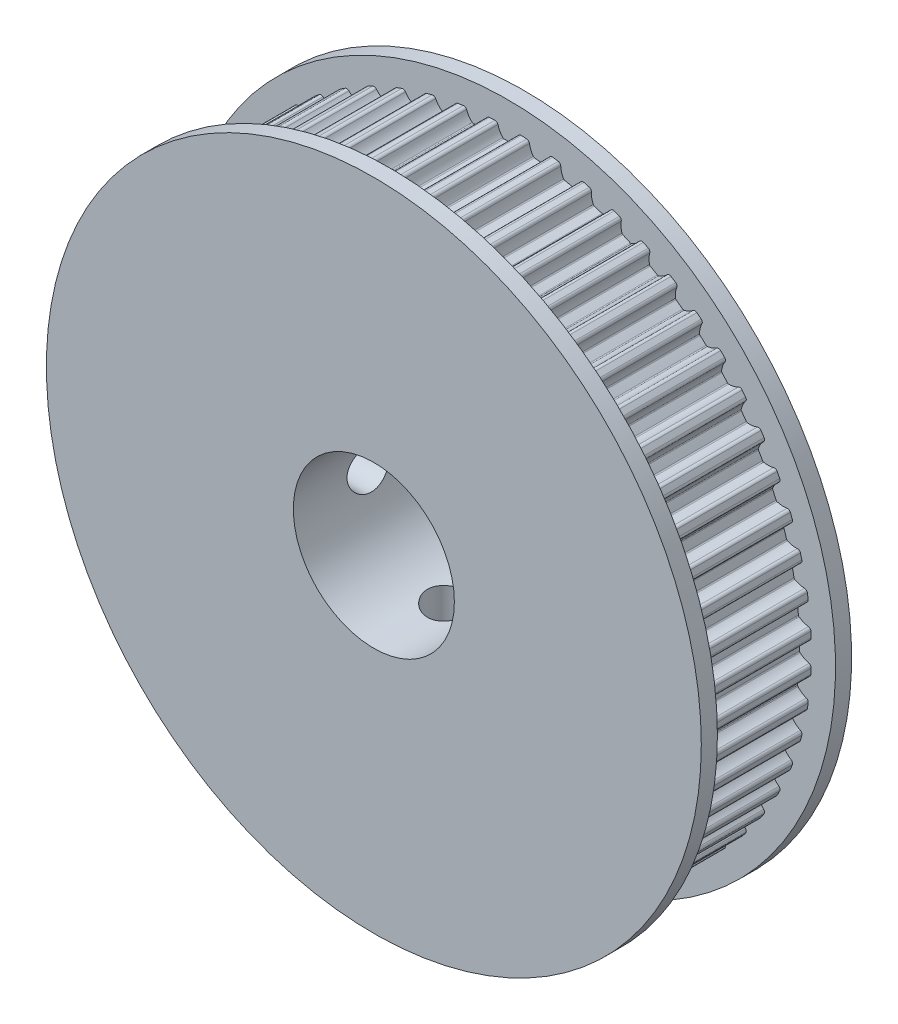
from build123d import *

# Parameters (mm, degrees)
SKETCH_1_R               = 28.265
EXTRUDE_1_DEPTH          = 5.5
CUT_EXTRUDE_START        = -12
CUT_EXTRUDE_1_DEPTH      = 13
PATTERN_CIRCULAR_1_COUNT = 60
SKETCH_3_R               = 30.5
EXTRUDE_2_DEPTH          = 1.5
SKETCH_9_R               = 30.5
EXTRUDE_3_DEPTH          = 1.5
SKETCH_4_R               = 7.5
CUT_EXTRUDE_2_DEPTH      = 15
SKETCH_10_R              = 2
CUT_EXTRUDE_3_DEPTH      = 31.5
SKETCH_11_R              = 2
CUT_EXTRUDE_4_DEPTH      = 31.5


with BuildPart() as part:
    # 草圖1 → 填料-伸長1 (new body, symmetric)
    with BuildSketch(Plane.XY):
        Circle(SKETCH_1_R)
    extrude(amount=EXTRUDE_1_DEPTH, both=True)

    # 草圖2 → 除料-伸長1 (cut)
    with BuildSketch(Plane.XY.offset(5.5).offset(CUT_EXTRUDE_START)):
        with BuildLine():
            ThreePointArc((-0.383112861, 27.152297316), (0, 27.155), (0.383112861, 27.152297316))
            ThreePointArc((0.383112861, 27.152297316), (0.445496306, 27.164922036), (0.49702877, 27.202278199))
            ThreePointArc((0.49702877, 27.202278199), (0.76723869, 27.588822948), (0.938098742, 28.028410353))
            ThreePointArc((0.938098742, 28.028410353), (1.042496742, 28.183734022), (1.221422579, 28.238596847))
            ThreePointArc((1.221422579, 28.238596847), (0, 28.265), (-1.221422579, 28.238596847))
            ThreePointArc((-1.221422579, 28.238596847), (-1.042496742, 28.183734022), (-0.938098742, 28.028410353))
            ThreePointArc((-0.938098742, 28.028410353), (-0.76723869, 27.588822948), (-0.49702877, 27.202278199))
            ThreePointArc((-0.49702877, 27.202278199), (-0.445496306, 27.164922036), (-0.383112861, 27.152297316))
        make_face()
    cut_extrude_1 = extrude(amount=CUT_EXTRUDE_1_DEPTH, mode=Mode.SUBTRACT)

    # 環狀複製排列1: 除料-伸長1 ×60 about axis
    pattern_circular_1_axis = Axis((0, 0, 0), (0, 0, 1))
    for i in range(1, PATTERN_CIRCULAR_1_COUNT):
        add(cut_extrude_1.rotate(pattern_circular_1_axis, i * 360 / PATTERN_CIRCULAR_1_COUNT), mode=Mode.SUBTRACT)

    # 草圖3 → 填料-伸長2 (add)
    with BuildSketch(Plane.XY.offset(5.5)):
        Circle(SKETCH_3_R)
    extrude(amount=EXTRUDE_2_DEPTH)

    # 草圖9 → 填料-伸長3 (add)
    with BuildSketch(Plane(origin=(0, 0, -5.5), x_dir=(-1, 0, 0), z_dir=(0, 0, -1))):
        Circle(SKETCH_9_R)
    extrude(amount=EXTRUDE_3_DEPTH)

    # 草圖4 → 除料-伸長2 (cut, through all)
    with BuildSketch(Plane.XY.offset(7)):
        Circle(SKETCH_4_R)
    extrude(amount=-CUT_EXTRUDE_2_DEPTH, mode=Mode.SUBTRACT)

    # 草圖10 → 除料-伸長3 (cut, through all)
    with BuildSketch(Plane(origin=(0, 0, 0), x_dir=(1, 0, 0), z_dir=(0, 1, 0))):
        Circle(SKETCH_10_R)
    extrude(amount=-CUT_EXTRUDE_3_DEPTH, mode=Mode.SUBTRACT)

    # 草圖11 → 除料-伸長4 (cut, through all)
    with BuildSketch(Plane(origin=(0, 0, 0), x_dir=(0, 0, -1), z_dir=(1, 0, 0))):
        Circle(SKETCH_11_R)
    extrude(amount=-CUT_EXTRUDE_4_DEPTH, mode=Mode.SUBTRACT)


solid = part.part
